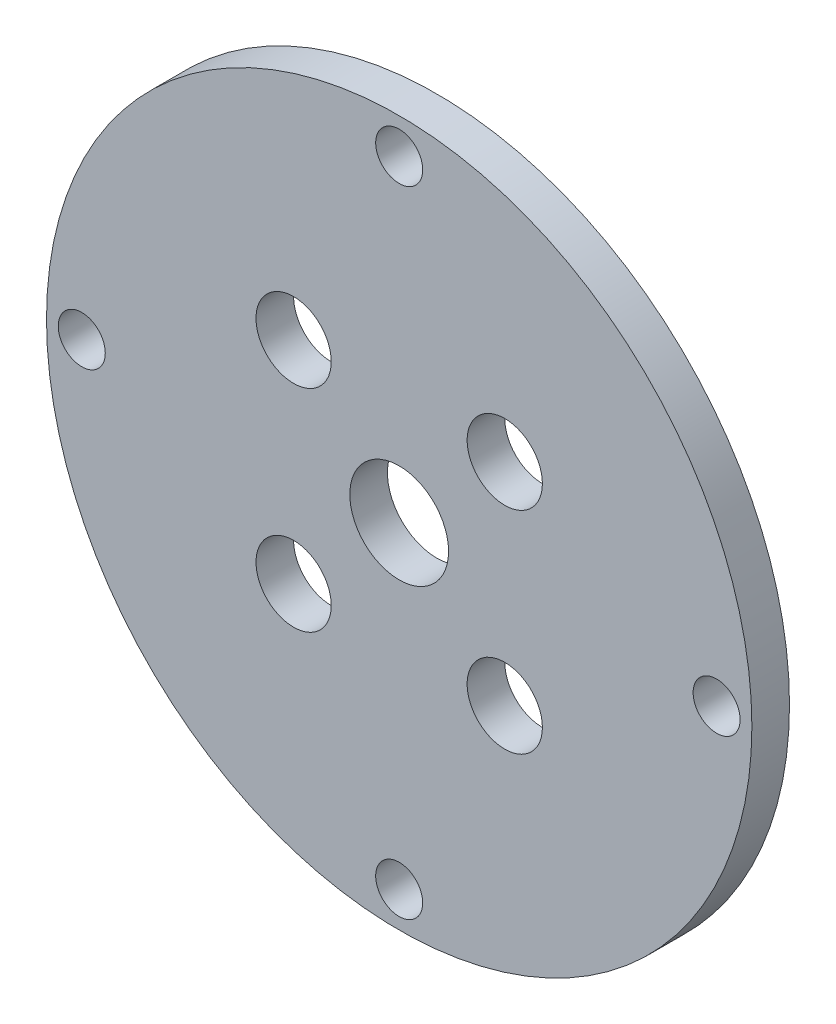
from build123d import *

# Parameters (mm, degrees)
SKETCH1_R           = 15
SKETCH1_R_2         = 2.1
SKETCH1_R_3         = 1.6
SKETCH1_R_4         = 1
BOSS_EXTRUDE1_DEPTH = 1.6


with BuildPart() as part:
    # Sketch1 → Boss-Extrude1 (new body)
    with BuildSketch(Plane.XY):
        Circle(SKETCH1_R)
        Circle(SKETCH1_R_2, mode=Mode.SUBTRACT)
        with Locations((4.490128061, 4.490128061)):
            Circle(SKETCH1_R_3, mode=Mode.SUBTRACT)
        with Locations((4.490128061, -4.490128061)):
            Circle(SKETCH1_R_3, mode=Mode.SUBTRACT)
        with Locations((-4.490128061, -4.490128061)):
            Circle(SKETCH1_R_3, mode=Mode.SUBTRACT)
        with Locations((-4.490128061, 4.490128061)):
            Circle(SKETCH1_R_3, mode=Mode.SUBTRACT)
        with Locations((0, 13.5)):
            Circle(SKETCH1_R_4, mode=Mode.SUBTRACT)
        with Locations((13.5, 0)):
            Circle(SKETCH1_R_4, mode=Mode.SUBTRACT)
        with Locations((0, -13.5)):
            Circle(SKETCH1_R_4, mode=Mode.SUBTRACT)
        with Locations((-13.5, 0)):
            Circle(SKETCH1_R_4, mode=Mode.SUBTRACT)
    extrude(amount=BOSS_EXTRUDE1_DEPTH)


solid = part.part
